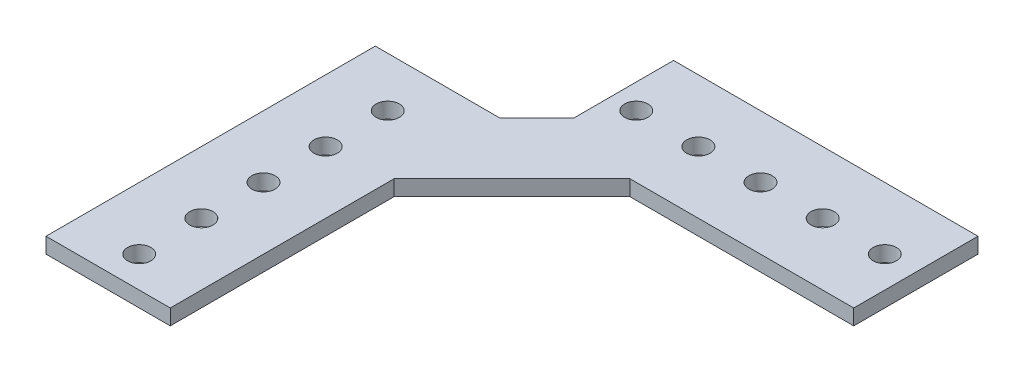
from build123d import *

# Parameters (mm, degrees)
SKETCH1_R           = 2.38125
BOSS_EXTRUDE1_DEPTH = 3.175


with BuildPart() as part:
    # Sketch1 → Boss-Extrude1 (new body)
    with BuildSketch(Plane(origin=(0, 0, 0), x_dir=(1, 0, 0), z_dir=(0, 1, 0))):
        Polygon((0, 67.31), (25.4, 67.31), (33.02, 74.93), (33.02, 95.25), (95.25, 95.25), (95.25, 69.85), (49.492614691, 69.85), (25.4, 45.757385309), (25.4, 0), (0, 0), align=None)
        with Locations((38.1, 82.55)):
            Circle(SKETCH1_R, mode=Mode.SUBTRACT)
        with Locations((12.7, 57.15)):
            Circle(SKETCH1_R, mode=Mode.SUBTRACT)
        with Locations((50.8, 82.55)):
            Circle(SKETCH1_R, mode=Mode.SUBTRACT)
        with Locations((63.5, 82.55)):
            Circle(SKETCH1_R, mode=Mode.SUBTRACT)
        with Locations((76.2, 82.55)):
            Circle(SKETCH1_R, mode=Mode.SUBTRACT)
        with Locations((88.9, 82.55)):
            Circle(SKETCH1_R, mode=Mode.SUBTRACT)
        with Locations((12.7, 44.45)):
            Circle(SKETCH1_R, mode=Mode.SUBTRACT)
        with Locations((12.7, 31.75)):
            Circle(SKETCH1_R, mode=Mode.SUBTRACT)
        with Locations((12.7, 19.05)):
            Circle(SKETCH1_R, mode=Mode.SUBTRACT)
        with Locations((12.7, 6.35)):
            Circle(SKETCH1_R, mode=Mode.SUBTRACT)
    extrude(amount=BOSS_EXTRUDE1_DEPTH)


solid = part.part
